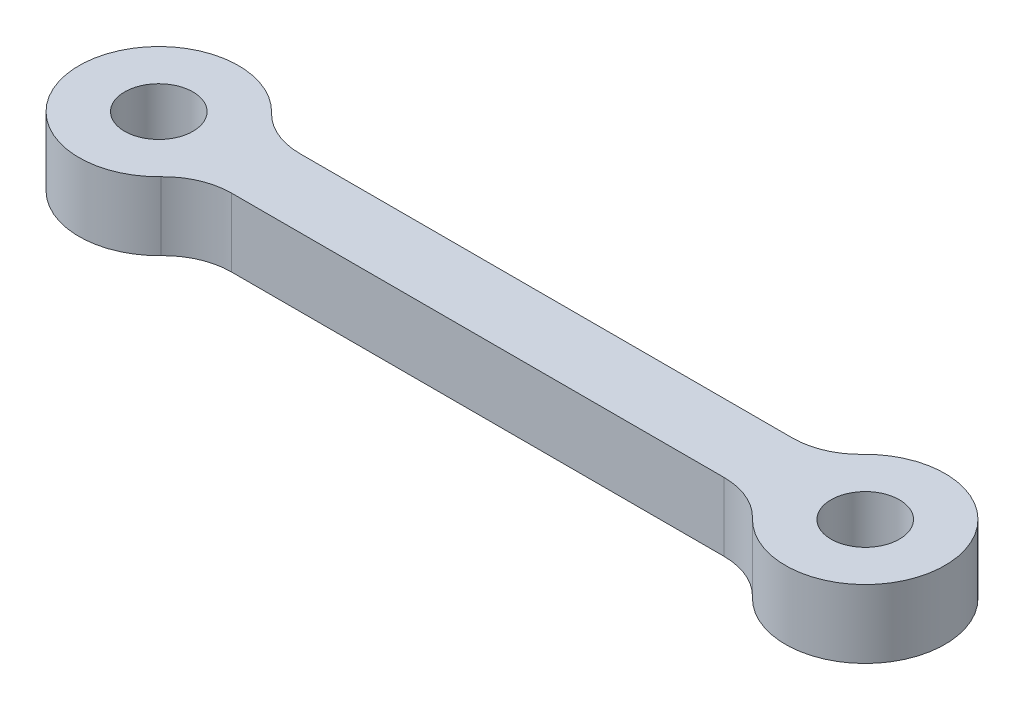
from build123d import *

# Parameters (mm, degrees)
SKETCH1_R           = 3.5
SKETCH1_R_2         = 1.5
BOSS_EXTRUDE1_DEPTH = 1.5
FILLET1_R           = 3


with BuildPart() as part:
    # Sketch1 → Boss-Extrude1 (new body, symmetric)
    with BuildSketch(Plane(origin=(0, 0, 0), x_dir=(1, 0, 0), z_dir=(0, 1, 0))):
        with BuildLine():
            ThreePointArc((-12, 0), (-12.085474278, -0.768774411), (-12.33772234, -1.5))
            Line((-12.33772234, -1.5), (12.33772234, -1.5))
            ThreePointArc((12.33772234, -1.5), (12, 0), (12.33772234, 1.5))
            Line((12.33772234, 1.5), (-12.33772234, 1.5))
            ThreePointArc((-12.33772234, 1.5), (-12.085474278, 0.768774411), (-12, 0))
        make_face()
        with Locations((-15.5, 0)):
            Circle(SKETCH1_R)
        with Locations((-15.5, 0)):
            Circle(SKETCH1_R_2, mode=Mode.SUBTRACT)
        with Locations((15.5, 0)):
            Circle(SKETCH1_R)
        with Locations((15.5, 0)):
            Circle(SKETCH1_R_2, mode=Mode.SUBTRACT)
    extrude(amount=BOSS_EXTRUDE1_DEPTH, both=True)

    # Fillet1
    fillet1_edges = [part.edges().sort_by_distance(p)[0] for p in [
        (12.33772234, 0, -1.5),
        (12.33772234, 0, 1.5),
        (-12.33772234, 0, 1.5),
        (-12.33772234, 0, -1.5),
    ]]
    fillet(fillet1_edges, radius=FILLET1_R)


solid = part.part
